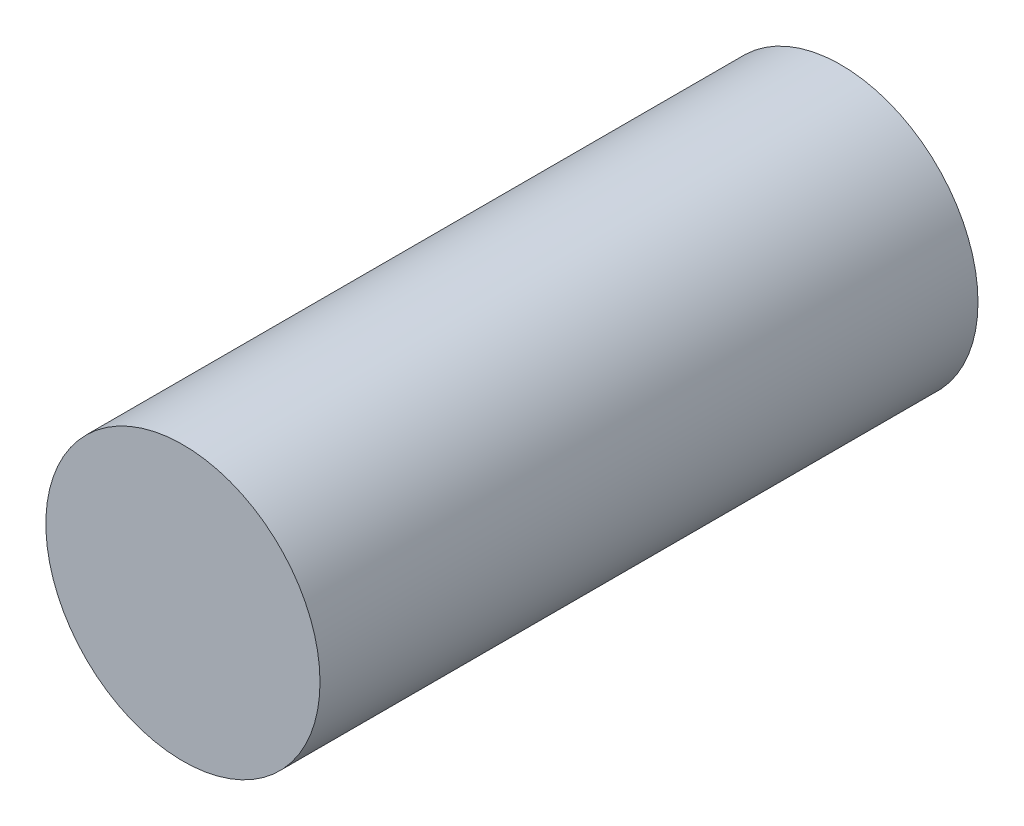
from build123d import *

# Parameters (mm, degrees)
SKETCH1_R           = 1.25
BOSS_EXTRUDE1_DEPTH = 6


with BuildPart() as part:
    # Sketch1 → Boss-Extrude1 (new body)
    with BuildSketch(Plane.XY):
        Circle(SKETCH1_R)
    extrude(amount=BOSS_EXTRUDE1_DEPTH)


solid = part.part
